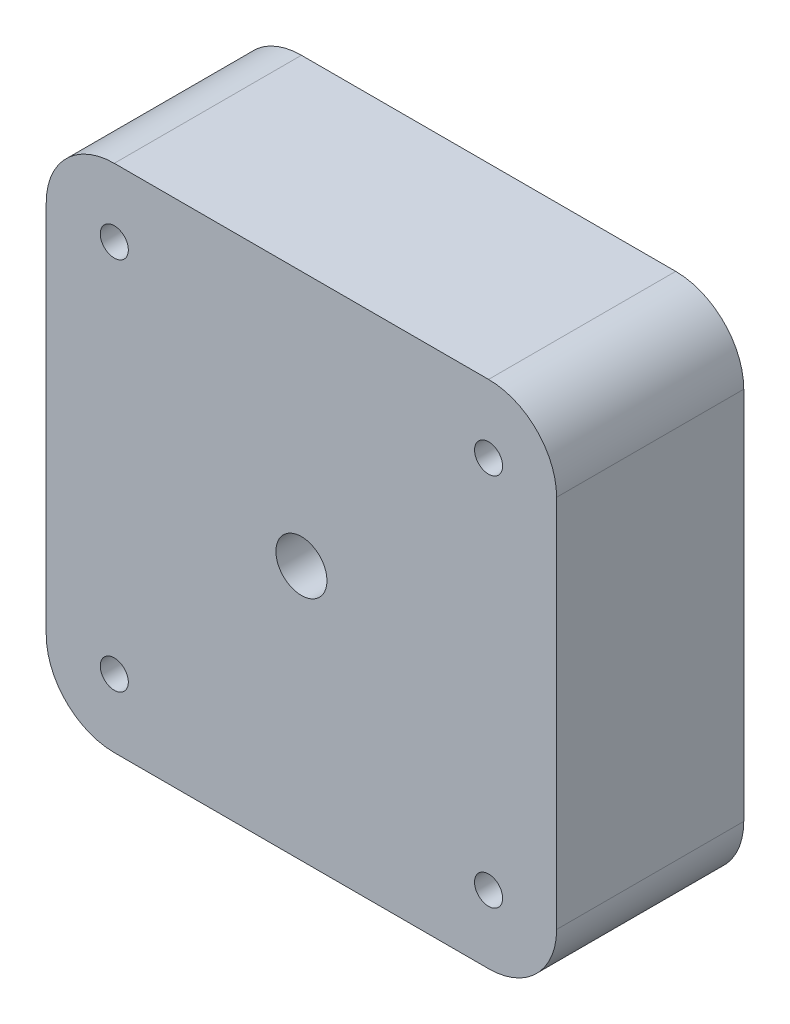
from build123d import *

# Parameters (mm, degrees)
SKETCH1_W             = 60
SKETCH1_H             = 60
BOSS_EXTRUDE1_DEPTH   = 22
SKETCH2_R             = 3
CUT_EXTRUDE1_DEPTH    = 23
CHAMFER1_SIZE         = 3
FILLET1_R             = 8
M4X0_7_TAPPED_HOLE1_D = 3.3


with BuildPart() as part:
    # Sketch1 → Boss-Extrude1 (new body)
    with BuildSketch(Plane.XY):
        Rectangle(SKETCH1_W, SKETCH1_H)
    extrude(amount=BOSS_EXTRUDE1_DEPTH)

    # Sketch2 → Cut-Extrude1 (cut, through all)
    with BuildSketch(Plane(origin=(0, 0, 0), x_dir=(-1, 0, 0), z_dir=(0, 0, -1))):
        Circle(SKETCH2_R)
    extrude(amount=-CUT_EXTRUDE1_DEPTH, mode=Mode.SUBTRACT)

    # Chamfer1
    chamfer1_edges = [part.edges().sort_by_distance(p)[0] for p in [
        (3, 0, 0),
    ]]
    chamfer(chamfer1_edges, length=CHAMFER1_SIZE)

    # Fillet1
    fillet1_edges = [part.edges().sort_by_distance(p)[0] for p in [
        (30, -30, 11),
        (-30, -30, 11),
        (-30, 30, 11),
        (30, 30, 11),
    ]]
    fillet(fillet1_edges, radius=FILLET1_R)

    # M4x0.7 Tapped Hole1 (through all)
    with Locations(Plane(origin=(0, 0, 0), x_dir=(-1, 0, 0), z_dir=(0, 0, -1))):
        with Locations((-22, 22), (22, 22), (22, -22), (-22, -22)):
            Hole(M4X0_7_TAPPED_HOLE1_D / 2)


solid = part.part
